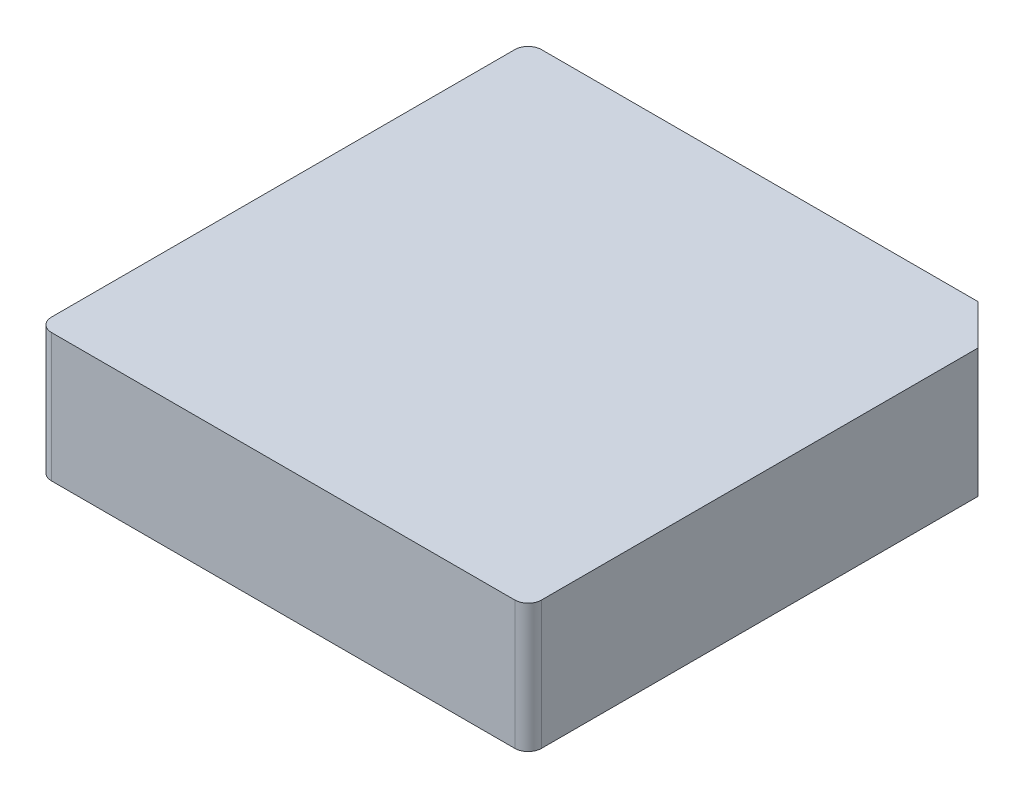
from build123d import *

# Parameters (mm, degrees)
BOSS_EXTRUDE1_DEPTH = 4.8
FILLET1_R           = 0.5
SKETCH2_R           = 0.475
BOSS_EXTRUDE2_DEPTH = 1.9


with BuildPart() as part:
    # Sketch1 → Boss-Extrude1 (new body)
    with BuildSketch(Plane(origin=(0, 0, 0), x_dir=(1, 0, 0), z_dir=(0, 1, 0))):
        Polygon((9.15, 7.65), (7.65, 9.15), (-9.15, 9.15), (-9.15, -9.15), (9.15, -9.15), align=None)
    extrude(amount=BOSS_EXTRUDE1_DEPTH)

    # Fillet1
    fillet1_edges = [part.edges().sort_by_distance(p)[0] for p in [
        (-9.15, 2.4, 9.15),
        (-9.15, 2.4, -9.15),
        (9.15, 2.4, 9.15),
    ]]
    fillet(fillet1_edges, radius=FILLET1_R)

    # Sketch2 → Boss-Extrude2 (add)
    with BuildSketch(Plane.XZ):
        with Locations(Location((0, 1.8, 0), (0, 0, 90))):  # turned: the seam where the file's is
            Circle(SKETCH2_R)
    extrude(amount=BOSS_EXTRUDE2_DEPTH)


solid = part.part
